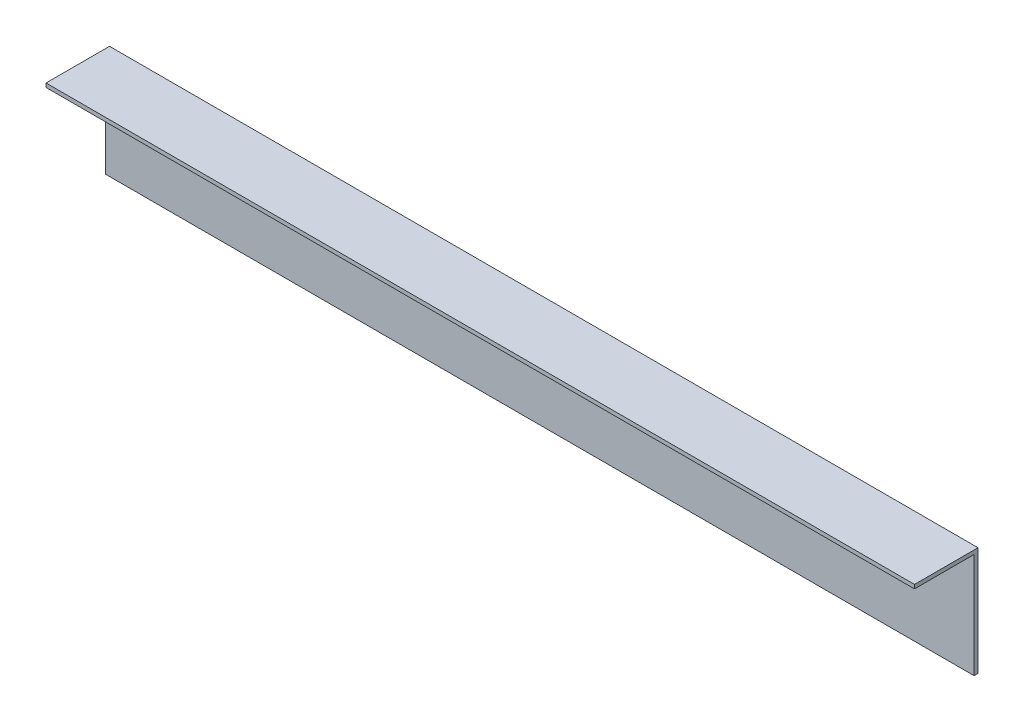
from build123d import *

# Parameters (mm, degrees)
SKETCH_1_W      = 335
SKETCH_1_H      = 42
EXTRUDE_1_DEPTH = 1.5
SKETCH_2_W      = 335
SKETCH_2_H      = 1.5
EXTRUDE_2_DEPTH = 23


with BuildPart() as part:
    # 草圖1 → 填料-伸長1 (new body)
    with BuildSketch(Plane.XY):
        with Locations((9.063621058, -47.510466989)):
            Rectangle(SKETCH_1_W, SKETCH_1_H)
    extrude(amount=EXTRUDE_1_DEPTH)

    # 草圖2 → 填料-伸長2 (add)
    with BuildSketch(Plane.XY.offset(1.5)):
        with Locations((9.063621058, -27.260466989)):
            Rectangle(SKETCH_2_W, SKETCH_2_H)
    extrude(amount=EXTRUDE_2_DEPTH)


solid = part.part
